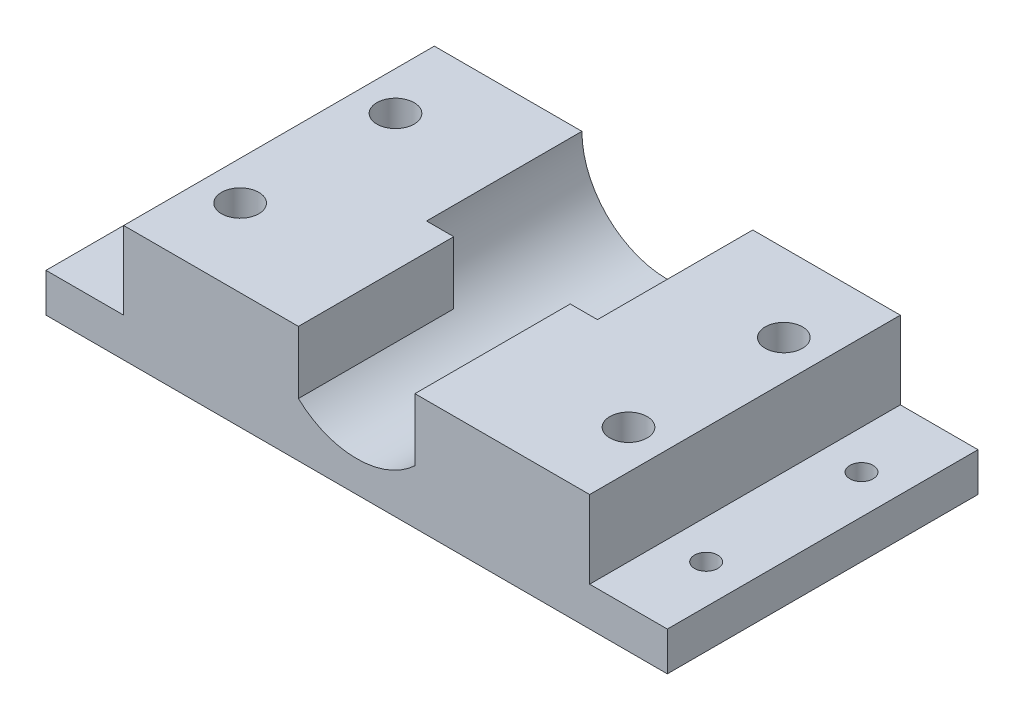
from build123d import *

# Parameters (mm, degrees)
BASE_MORS_DEPTH                    = 40
ESQUISSE2_R                        = 11
EMPLACEMENT_MOTEUR_DEPTH           = 41
ESQUISSE3_R                        = 1.5
TROU_FIXATIONS_BASE_DEPTH          = 6
ESQUISSE4_R                        = 2.4
TROU_FIXATION_MORS_SUPERIEUR_DEPTH = 6
ESQUISSE6_W                        = 3.5
ESQUISSE6_H                        = 12
ENCOCHE_MOTEUR_DEPTH               = 20


with BuildPart() as part:
    # Esquisse1 → base_mors (new body)
    with BuildSketch(Plane.XY):
        Polygon((60, 15), (60, 5), (70, 5), (70, 0), (60, 0), (0, 0), (-10, 0), (-10, 5), (0, 5), (0, 15), align=None)
    extrude(amount=BASE_MORS_DEPTH)

    # Esquisse2 → emplacement_moteur (cut, through all)
    with BuildSketch(Plane.XY.offset(40)):
        with Locations((30, 15)):
            Circle(ESQUISSE2_R)
    extrude(amount=-EMPLACEMENT_MOTEUR_DEPTH, mode=Mode.SUBTRACT)

    # Esquisse3 → trou_fixations_base (cut, through all)
    with BuildSketch(Plane(origin=(0, 5, 0), x_dir=(1, 0, 0), z_dir=(0, 1, 0))):
        with Locations((-5, -10)):
            Circle(ESQUISSE3_R)
        with Locations((65, -10)):
            Circle(ESQUISSE3_R)
        with Locations((65, -30)):
            Circle(ESQUISSE3_R)
        with Locations((-5, -30)):
            Circle(ESQUISSE3_R)
    extrude(amount=-TROU_FIXATIONS_BASE_DEPTH, mode=Mode.SUBTRACT)

    # Esquisse4 → trou_fixation_mors_superieur (cut)
    with BuildSketch(Plane(origin=(0, 15, 0), x_dir=(1, 0, 0), z_dir=(0, 1, 0))):
        with Locations((5, -10)):
            Circle(ESQUISSE4_R)
        with Locations((55, -10)):
            Circle(ESQUISSE4_R)
        with Locations((55, -30)):
            Circle(ESQUISSE4_R)
        with Locations((5, -30)):
            Circle(ESQUISSE4_R)
    extrude(amount=-TROU_FIXATION_MORS_SUPERIEUR_DEPTH, mode=Mode.SUBTRACT)

    # Esquisse6 → encoche moteur (add)
    with BuildSketch(Plane.XY.offset(40)):
        with Locations((20.75, 9)):
            Rectangle(ESQUISSE6_W, ESQUISSE6_H)
        with Locations((39.25, 9)):
            Rectangle(ESQUISSE6_W, ESQUISSE6_H)
    extrude(amount=-ENCOCHE_MOTEUR_DEPTH)


solid = part.part
